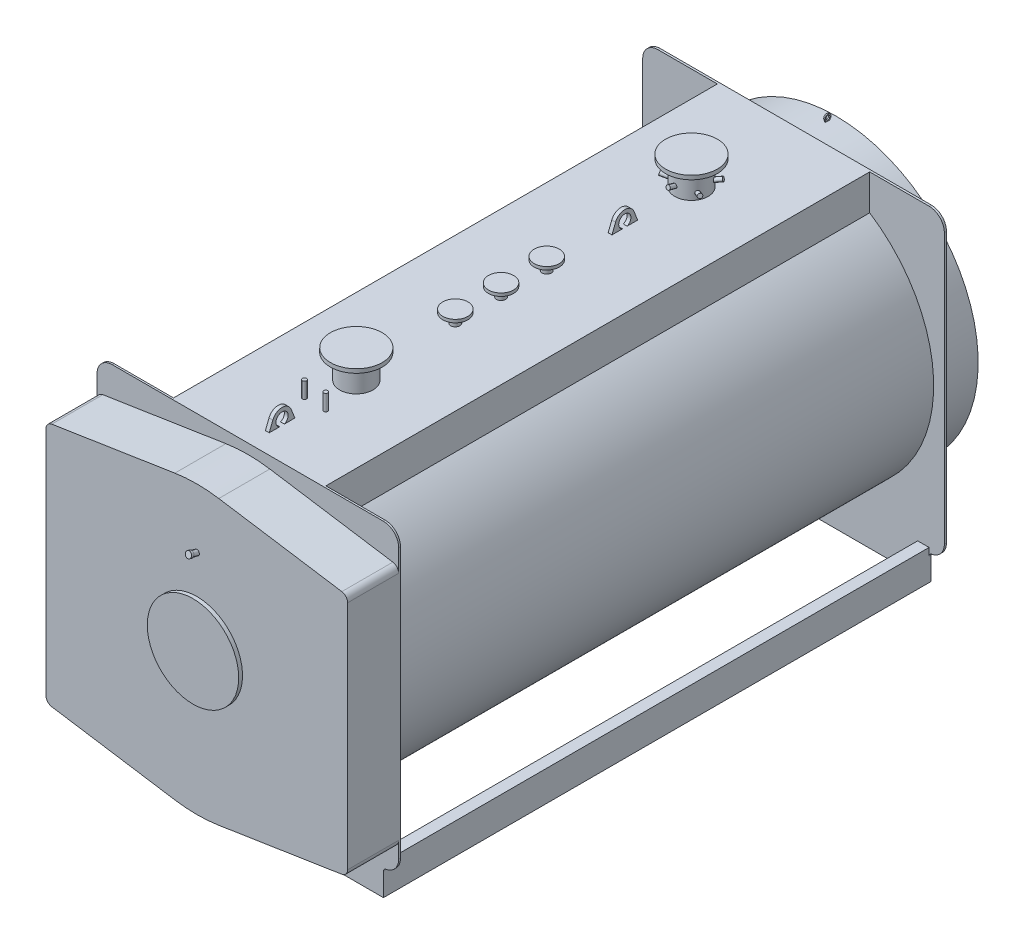
from build123d import *

# Parameters (mm, degrees)
PIASTRA_ANTERIORE_DEPTH       = 12
CORPO_DEPTH                   = 3570
PIASTRA_POSTERIORE_DEPTH      = 14
BASAMENTO_DEPTH               = 3570
SCHIZZO24_R                   = 13.35
ESTRUSIONE_ESTRUSIONE12_DEPTH = 298
SCHIZZO25_R                   = 81
ESTRUSIONE_ESTRUSIONE13_DEPTH = 8
SCHIZZO31_R                   = 12.5
ESTRUSIONE_ESTRUSIONE15_DEPTH = 4
SCHIZZO11_R                   = 16.85
SCHIZZO21_R                   = 109.55
ESTRUSIONE_ESTRUSIONE9_DEPTH  = 1191
SCHIZZO22_R                   = 170
ESTRUSIONE_ESTRUSIONE10_DEPTH = 26
SCHIZZO21_4_R                 = 30.15
ESTRUSIONE_ESTRUSIONE11_DEPTH = 1085
SCHIZZO35_R                   = 82.5
ESTRUSIONE_ESTRUSIONE16_DEPTH = 20
SCHIZZO21_6_R                 = 13.35
ESTRUSIONE_ESTRUSIONE18_DEPTH = 1110
RIPETIZIONECIRCOLARE1_COUNT   = 3
ESTRUSIONE_ESTRUSIONE5_DEPTH  = 335
SCHIZZO15_R                   = 300
ESTRUSIONE_ESTRUSIONE6_DEPTH  = 25
SCHIZZO37_R                   = 40
ESTRUSIONE_ESTRUSIONE17_DEPTH = 12.5


with BuildPart() as part:
    # Schizzo1 → piastra anteriore (new body)
    with BuildSketch(Plane.XY):
        with BuildLine():
            Line((-890, 2140), (890, 2140))
            ThreePointArc((890, 2140), (960.710678119, 2110.710678119), (990, 2040))
            Line((990, 2040), (990, 268.601329718))
            ThreePointArc((990, 268.601329718), (966.376261583, 204.051607282), (906.666666667, 170))
            ThreePointArc((906.666666667, 170), (894.724747683, 163.189678544), (890, 150.279734056))
            Line((890, 150.279734056), (890, 0))
            Line((890, 0), (-890, 0))
            Line((-890, 0), (-890, 150.279734056))
            ThreePointArc((-890, 150.279734056), (-894.724747683, 163.189678544), (-906.666666667, 170))
            ThreePointArc((-906.666666667, 170), (-966.376261583, 204.051607282), (-990, 268.601329718))
            Line((-990, 268.601329718), (-990, 2040))
            ThreePointArc((-990, 2040), (-960.710678119, 2110.710678119), (-890, 2140))
        make_face()
    extrude(amount=-PIASTRA_ANTERIORE_DEPTH)

    # Schizzo2 → corpo (add)
    with BuildSketch(Plane(origin=(0, 0, -12), x_dir=(-1, 0, 0), z_dir=(0, 0, -1))):
        with BuildLine():
            Line((500, 1907.269383052), (500, 2140))
            Line((500, 2140), (-500, 2140))
            Line((-500, 2140), (-500, 1907.269383052))
            ThreePointArc((-500, 1907.269383052), (0, 215), (500, 1907.269383052))
        make_face()
    extrude(amount=CORPO_DEPTH)

    # Schizzo3 → piastra posteriore (add)
    with BuildSketch(Plane(origin=(0, 0, -3582), x_dir=(-1, 0, 0), z_dir=(0, 0, -1))):
        with BuildLine():
            Line((-890, 150.279734056), (-890, 0))
            Line((-890, 0), (890, 0))
            Line((890, 0), (890, 150.279734056))
            ThreePointArc((890, 150.279734056), (894.724747683, 163.189678544), (906.666666667, 170))
            ThreePointArc((906.666666667, 170), (966.376261583, 204.051607282), (990, 268.601329718))
            Line((990, 268.601329718), (990, 2040))
            ThreePointArc((990, 2040), (960.710678119, 2110.710678119), (890, 2140))
            Line((890, 2140), (-890, 2140))
            ThreePointArc((-890, 2140), (-960.710678119, 2110.710678119), (-990, 2040))
            Line((-990, 2040), (-990, 268.601329718))
            ThreePointArc((-990, 268.601329718), (-966.376261583, 204.051607282), (-906.666666667, 170))
            ThreePointArc((-906.666666667, 170), (-894.724747683, 163.189678544), (-890, 150.279734056))
        make_face()
    extrude(amount=PIASTRA_POSTERIORE_DEPTH)

    # Schizzo4 → basamento (add)
    with BuildSketch(Plane(origin=(0, 0, -12), x_dir=(-1, 0, 0), z_dir=(0, 0, -1))):
        Polygon((-815, 0), (-890, 0), (-890, 200), (-815, 200), (-815, 192), (-882, 192), (-882, 8), (-815, 8), align=None)
    extrude(amount=BASAMENTO_DEPTH)

    # Schizzo23 → camera-fumo (revolve)
    with BuildSketch(Plane(origin=(0, 0, 0), x_dir=(0, 0, -1), z_dir=(1, 0, 0))):
        Polygon((3596, 2070), (3859, 2070), (3859, 1434), (3904, 1434), (3904, 1475), (3909, 1475), (3909, 1429), (3854, 1429), (3854, 2065), (3596, 2065), align=None)
    revolve(axis=Axis((0, 1135, -4219.232253574), (0, 0, 1)))

    # Schizzo24 → Estrusione-Estrusione12 (add)
    with BuildSketch(Plane(origin=(0, 0, -3596), x_dir=(-1, 0, 0), z_dir=(0, 0, -1))):
        with Locations(Location((0, 215.5, 0), (0, 0, 270))):  # turned: the seam where the file's is
            Circle(SCHIZZO24_R)
    extrude(amount=ESTRUSIONE_ESTRUSIONE12_DEPTH)

    # Schizzo25 → Estrusione-Estrusione13 (add)
    with BuildSketch(Plane(origin=(0, 0, -3859), x_dir=(-1, 0, 0), z_dir=(0, 0, -1))):
        with Locations(Location((0, 395, 0), (0, 0, 270))):  # turned: the seam where the file's is
            Circle(SCHIZZO25_R)
    extrude(amount=ESTRUSIONE_ESTRUSIONE13_DEPTH)

    # Schizzo31 → Estrusione-Estrusione15 (add, symmetric)
    with BuildSketch(Plane(origin=(0, 0, 0), x_dir=(0, 0, -1), z_dir=(1, 0, 0))):
        with BuildLine():
            Line((3789, 2065), (3789, 2076.771243445))
            ThreePointArc((3789, 2076.771243445), (3804, 2110), (3819, 2076.771243445))
            Line((3819, 2076.771243445), (3819, 2065))
            Line((3819, 2065), (3789, 2065))
        make_face()
        with Locations((3804, 2090)):
            Circle(SCHIZZO31_R, mode=Mode.SUBTRACT)
    extrude(amount=ESTRUSIONE_ESTRUSIONE15_DEPTH, both=True)

    # Sweep1: sweep along a path in Schizzo10
    with BuildLine(Plane(origin=(0, 0, 0), x_dir=(0, 0, -1), z_dir=(1, 0, 0))) as sweep1_path:
        Line((3452, 320), (3452, 120))
        ThreePointArc((3452, 120), (3469.573593129, 77.573593129), (3512, 60))
        Line((3512, 60), (4007, 60))
    # Schizzo11 → Sweep1 (sweep)
    with BuildSketch(Plane(origin=(0, 60, -4007), x_dir=(-1, 0, 0), z_dir=(0, 0, -1))):
        Circle(SCHIZZO11_R)
    sweep(path=sweep1_path.line)

    # Schizzo21 → Estrusione-Estrusione9 (add)
    with BuildSketch(Plane(origin=(0, 1135, 0), x_dir=(1, 0, 0), z_dir=(0, 1, 0))):
        with Locations(Location((0, 712, 0), (0, 0, 270))):  # turned: the seam where the file's is
            Circle(SCHIZZO21_R)
        with Locations(Location((0, 2912, 0), (0, 0, 270))):  # turned: the seam where the file's is
            Circle(SCHIZZO21_R)
    extrude(amount=ESTRUSIONE_ESTRUSIONE9_DEPTH)

    # Schizzo22 → Estrusione-Estrusione10 (add)
    with BuildSketch(Plane(origin=(0, 2326, 0), x_dir=(1, 0, 0), z_dir=(0, 1, 0))):
        with Locations(Location((0, 712, 0), (0, 0, 270))):  # turned: the seam where the file's is
            Circle(SCHIZZO22_R)
        with Locations(Location((0, 2912, 0), (0, 0, 270))):  # turned: the seam where the file's is
            Circle(SCHIZZO22_R)
    extrude(amount=-ESTRUSIONE_ESTRUSIONE10_DEPTH)

    # Schizzo21_4 → Estrusione-Estrusione11 (add)
    with BuildSketch(Plane(origin=(0, 1135, 0), x_dir=(1, 0, 0), z_dir=(0, 1, 0))):
        with Locations(Location((0, 1962, 0), (0, 0, 270))):  # turned: the seam where the file's is
            Circle(SCHIZZO21_4_R)
        with Locations(Location((0, 1362, 0), (0, 0, 270))):  # turned: the seam where the file's is
            Circle(SCHIZZO21_4_R)
        with Locations(Location((0, 1662, 0), (0, 0, 270))):  # turned: the seam where the file's is
            Circle(SCHIZZO21_4_R)
    extrude(amount=ESTRUSIONE_ESTRUSIONE11_DEPTH)

    # Schizzo35 → Estrusione-Estrusione16 (add)
    with BuildSketch(Plane(origin=(0, 2220, 0), x_dir=(1, 0, 0), z_dir=(0, 1, 0))):
        with Locations(Location((0, 1362, 0), (0, 0, 270))):  # turned: the seam where the file's is
            Circle(SCHIZZO35_R)
        with Locations(Location((0, 1662, 0), (0, 0, 270))):  # turned: the seam where the file's is
            Circle(SCHIZZO35_R)
        with Locations(Location((0, 1962, 0), (0, 0, 270))):  # turned: the seam where the file's is
            Circle(SCHIZZO35_R)
    extrude(amount=-ESTRUSIONE_ESTRUSIONE16_DEPTH)

    # Schizzo21_6 → Estrusione-Estrusione18 (add)
    with BuildSketch(Plane(origin=(0, 1135, 0), x_dir=(1, 0, 0), z_dir=(0, 1, 0))):
        with Locations(Location((-70, 442, 0), (0, 0, 270))):  # turned: the seam where the file's is
            Circle(SCHIZZO21_6_R)
        with Locations(Location((70, 442, 0), (0, 0, 270))):  # turned: the seam where the file's is
            Circle(SCHIZZO21_6_R)
    extrude(amount=ESTRUSIONE_ESTRUSIONE18_DEPTH)

    # Schizzo9 → Rivoluzione3 (revolve)
    with BuildSketch(Plane(origin=(0, 0, 0), x_dir=(0, 0, -1), z_dir=(1, 0, 0))):
        Polygon((3003.55, 2190.101379163), (3061.505549577, 2205.630521869), (3064.986665734, 2192.638819505), (3007.031116157, 2177.109676799), align=None)
    rivoluzione3 = revolve(axis=Axis((0, 2181, -3021.55), (0, -0.258819045, 0.965925826)))

    # Schizzo34 → Rivoluzione5 (revolve)
    with BuildSketch(Plane(origin=(0, 0, 0), x_dir=(0, 0, -1), z_dir=(1, 0, 0))):
        Polygon((2762.494450423, 2225.630521869), (2820.45, 2210.101379163), (2816.968883843, 2197.109676799), (2759.013334266, 2212.638819505), align=None)
    rivoluzione5 = revolve(axis=Axis((0, 2201, -2802.45), (0, 0.258819045, 0.965925826)))

    # RipetizioneCircolare1: Rivoluzione3, Rivoluzione5 ×3 about axis
    ripetizionecircolare1_axis = Axis((0, 0, -2912), (0, 1, 0))
    add([rivoluzione3.rotate(ripetizionecircolare1_axis, i * 360 / RIPETIZIONECIRCOLARE1_COUNT) for i in range(1, RIPETIZIONECIRCOLARE1_COUNT)])
    add([rivoluzione5.rotate(ripetizionecircolare1_axis, i * 360 / RIPETIZIONECIRCOLARE1_COUNT) for i in range(1, RIPETIZIONECIRCOLARE1_COUNT)])

    # Schizzo33 → Rivoluzione4 (revolve)
    with BuildSketch(Plane(origin=(0, 0, 0), x_dir=(0, 0, -1), z_dir=(1, 0, 0)), mode=Mode.PRIVATE) as rivoluzione4_sk:
        Polygon((803.55, 2215.101379163), (861.505549577, 2230.630521869), (864.986665734, 2217.638819505), (807.031116157, 2202.109676799), align=None)
    revolve(rivoluzione4_sk.sketch.rotate(Axis((0, 2206, -821.55), (0, 0.258819045, -0.965925826)), 180), axis=Axis((0, 2206, -821.55), (0, 0.258819045, -0.965925826)))  # turned: the seam where the file's is

    # Schizzo14 → Estrusione-Estrusione5 (add)
    with BuildSketch(Plane.XY):
        with BuildLine():
            Line((-990, 1894), (-990, 376))
            ThreePointArc((-990, 376), (-979.173710049, 346.722747029), (-951.904109267, 331.532784265))
            Line((-951.904109267, 331.532784265), (-144.219171349, 206.129271311))
            ThreePointArc((-144.219171349, 206.129271311), (0, 195), (144.219171349, 206.129271311))
            Line((144.219171349, 206.129271311), (951.904109267, 331.532784265))
            ThreePointArc((951.904109267, 331.532784265), (979.173710049, 346.722747029), (990, 376))
            Line((990, 376), (990, 1894))
            ThreePointArc((990, 1894), (979.173710049, 1923.277252971), (951.904109267, 1938.467215735))
            Line((951.904109267, 1938.467215735), (144.219171349, 2063.870728689))
            ThreePointArc((144.219171349, 2063.870728689), (0, 2075), (-144.219171349, 2063.870728689))
            Line((-144.219171349, 2063.870728689), (-951.904109267, 1938.467215735))
            ThreePointArc((-951.904109267, 1938.467215735), (-979.173710049, 1923.277252971), (-990, 1894))
        make_face()
    extrude(amount=ESTRUSIONE_ESTRUSIONE5_DEPTH)

    # Schizzo15 → Estrusione-Estrusione6 (add)
    with BuildSketch(Plane.XY.offset(335)):
        with Locations(Location((0, 1135, 0), (0, 0, 180))):  # turned: the seam where the file's is
            Circle(SCHIZZO15_R)
    extrude(amount=ESTRUSIONE_ESTRUSIONE6_DEPTH)

    # Schizzo18 → Rivoluzione2 (revolve)
    with BuildSketch(Plane(origin=(0, 0, 0), x_dir=(0, 0, -1), z_dir=(1, 0, 0))):
        Polygon((-370.241857968, 1711.887431022), (-369.426577976, 1714.930097375), (-384.881391196, 1719.071202097), (-390.057772098, 1699.752685571), (-315, 1679.641016151), (-310.63889909, 1695.916866324), align=None)
    revolve(axis=Axis((0, 1685, 335), (0, 0.258819045, 0.965925826)))

    # Schizzo37 → Estrusione-Estrusione17 (add, symmetric)
    with BuildSketch(Plane(origin=(0, 0, 0), x_dir=(0, 0, -1), z_dir=(1, 0, 0))):
        with BuildLine():
            Line((117, 2062), (117, 2112))
            Line((117, 2112), (151.41509434, 2200.547169811))
            ThreePointArc((151.41509434, 2200.547169811), (212, 2242), (272.58490566, 2200.547169811))
            Line((272.58490566, 2200.547169811), (307, 2112))
            Line((307, 2112), (307, 2062))
            Line((307, 2062), (117, 2062))
        make_face()
        with Locations((212, 2177)):
            Circle(SCHIZZO37_R, mode=Mode.SUBTRACT)
        with BuildLine():
            Line((2367, 2062), (2367, 2112))
            Line((2367, 2112), (2401.41509434, 2200.547169811))
            ThreePointArc((2401.41509434, 2200.547169811), (2462, 2242), (2522.58490566, 2200.547169811))
            Line((2522.58490566, 2200.547169811), (2557, 2112))
            Line((2557, 2112), (2557, 2062))
            Line((2557, 2062), (2367, 2062))
        make_face()
        with Locations((2462, 2177)):
            Circle(SCHIZZO37_R, mode=Mode.SUBTRACT)
    extrude(amount=ESTRUSIONE_ESTRUSIONE17_DEPTH, both=True)


solid = part.part
